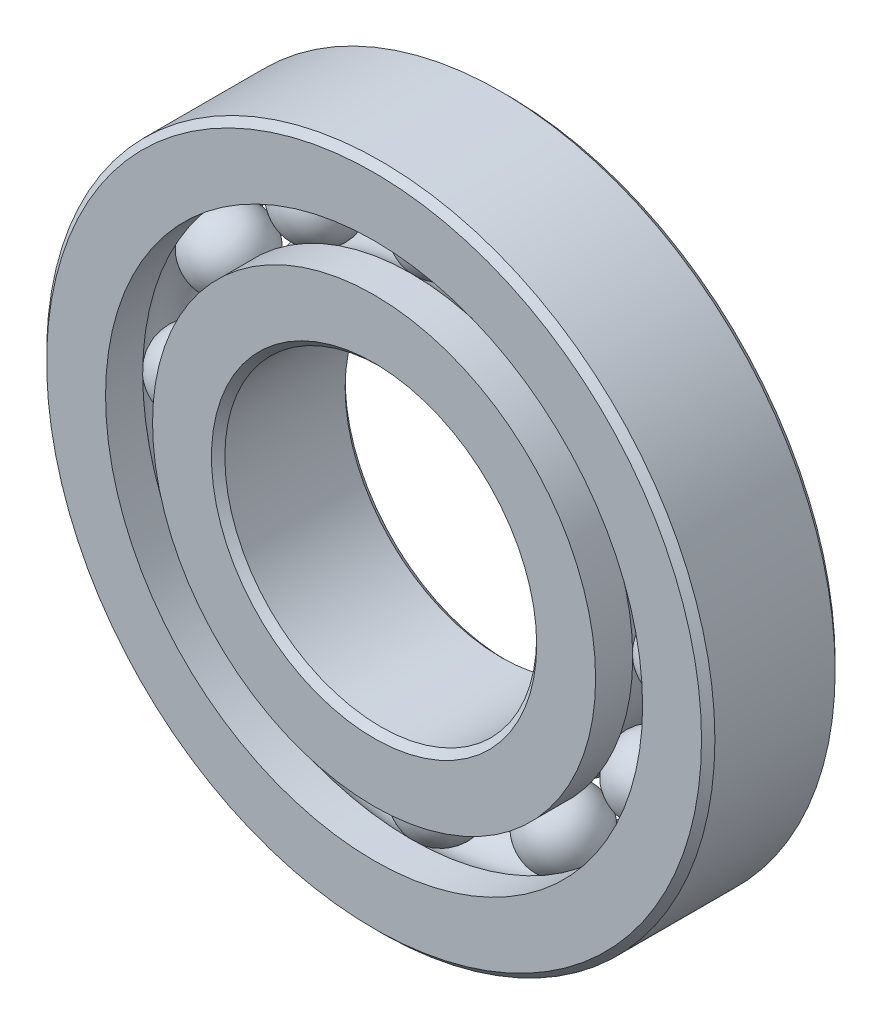
from build123d import *

# Parameters (mm, degrees)
CIRPATTERN1_COUNT = 12


with BuildPart() as part:
    # Sketch1 → Revolve1 (revolve)
    with BuildSketch(Plane(origin=(0, 0, 0), x_dir=(0, 0, -1), z_dir=(1, 0, 0))):
        with BuildLine():
            Line((4.28625, 23.8125), (-4.28625, 23.8125))
            Line((-4.28625, 23.8125), (-4.7625, 23.33625))
            Line((-4.7625, 23.33625), (-4.7625, 19.137225275))
            Line((-4.7625, 19.137225275), (-2.116666667, 19.137225275))
            ThreePointArc((-2.116666667, 19.137225275), (0, 20.161570678), (2.116666667, 19.137225275))
            Line((2.116666667, 19.137225275), (4.7625, 19.137225275))
            Line((4.7625, 19.137225275), (4.7625, 23.33625))
            Line((4.7625, 23.33625), (4.28625, 23.8125))
        make_face()
    revolve(axis=Axis((0, 0, 4.7625), (0, 0, -1)))


with BuildPart() as body_2:
    # Sketch3 → Revolve3 (revolve)
    with BuildSketch(Plane(origin=(0, 0, 0), x_dir=(0, 0, -1), z_dir=(1, 0, 0))):
        with BuildLine():
            Line((-4.7625, 15.787774725), (-2.116666667, 15.787774725))
            ThreePointArc((-2.116666667, 15.787774725), (0, 14.763429322), (2.116666667, 15.787774725))
            Line((2.116666667, 15.787774725), (4.7625, 15.787774725))
            Line((4.7625, 15.787774725), (4.7625, 11.58875))
            Line((4.7625, 11.58875), (4.28625, 11.1125))
            Line((4.28625, 11.1125), (-4.28625, 11.1125))
            Line((-4.28625, 11.1125), (-4.7625, 11.58875))
            Line((-4.7625, 11.58875), (-4.7625, 15.787774725))
        make_face()
    revolve(axis=Axis((0, 0, 4.7625), (0, 0, -1)))


with BuildPart() as body_3:
    # Sketch4 → Revolve4 (revolve)
    with BuildSketch(Plane(origin=(0, 0, 0), x_dir=(0, 0, -1), z_dir=(1, 0, 0))):
        with BuildLine():
            Line((-2.699070678, 17.4625), (2.699070678, 17.4625))
            ThreePointArc((2.699070678, 17.4625), (0, 20.161570678), (-2.699070678, 17.4625))
        make_face()
    revolve(axis=Axis((0, 17.4625, 2.699070678), (0, 0, -1)))


with BuildPart() as cirpattern1_1:
    # CirPattern1: pattern copy
    add(body_3.part.rotate(Axis((0, 0, -4.7625), (0, 0, 1)), 1 * 360 / CIRPATTERN1_COUNT))


with BuildPart() as cirpattern1_2:
    # CirPattern1: pattern copy
    add(body_3.part.rotate(Axis((0, 0, -4.7625), (0, 0, 1)), 2 * 360 / CIRPATTERN1_COUNT))


with BuildPart() as cirpattern1_3:
    # CirPattern1: pattern copy
    add(body_3.part.rotate(Axis((0, 0, -4.7625), (0, 0, 1)), 3 * 360 / CIRPATTERN1_COUNT))


with BuildPart() as cirpattern1_4:
    # CirPattern1: pattern copy
    add(body_3.part.rotate(Axis((0, 0, -4.7625), (0, 0, 1)), 4 * 360 / CIRPATTERN1_COUNT))


with BuildPart() as cirpattern1_5:
    # CirPattern1: pattern copy
    add(body_3.part.rotate(Axis((0, 0, -4.7625), (0, 0, 1)), 5 * 360 / CIRPATTERN1_COUNT))


with BuildPart() as cirpattern1_6:
    # CirPattern1: pattern copy
    add(body_3.part.rotate(Axis((0, 0, -4.7625), (0, 0, 1)), 6 * 360 / CIRPATTERN1_COUNT))


with BuildPart() as cirpattern1_7:
    # CirPattern1: pattern copy
    add(body_3.part.rotate(Axis((0, 0, -4.7625), (0, 0, 1)), 7 * 360 / CIRPATTERN1_COUNT))


with BuildPart() as cirpattern1_8:
    # CirPattern1: pattern copy
    add(body_3.part.rotate(Axis((0, 0, -4.7625), (0, 0, 1)), 8 * 360 / CIRPATTERN1_COUNT))


with BuildPart() as cirpattern1_9:
    # CirPattern1: pattern copy
    add(body_3.part.rotate(Axis((0, 0, -4.7625), (0, 0, 1)), 9 * 360 / CIRPATTERN1_COUNT))


with BuildPart() as cirpattern1_10:
    # CirPattern1: pattern copy
    add(body_3.part.rotate(Axis((0, 0, -4.7625), (0, 0, 1)), 10 * 360 / CIRPATTERN1_COUNT))


with BuildPart() as cirpattern1_11:
    # CirPattern1: pattern copy
    add(body_3.part.rotate(Axis((0, 0, -4.7625), (0, 0, 1)), 11 * 360 / CIRPATTERN1_COUNT))


solid = Compound([part.part, body_2.part, body_3.part, cirpattern1_1.part, cirpattern1_2.part, cirpattern1_3.part, cirpattern1_4.part, cirpattern1_5.part, cirpattern1_6.part, cirpattern1_7.part, cirpattern1_8.part, cirpattern1_9.part, cirpattern1_10.part, cirpattern1_11.part])
